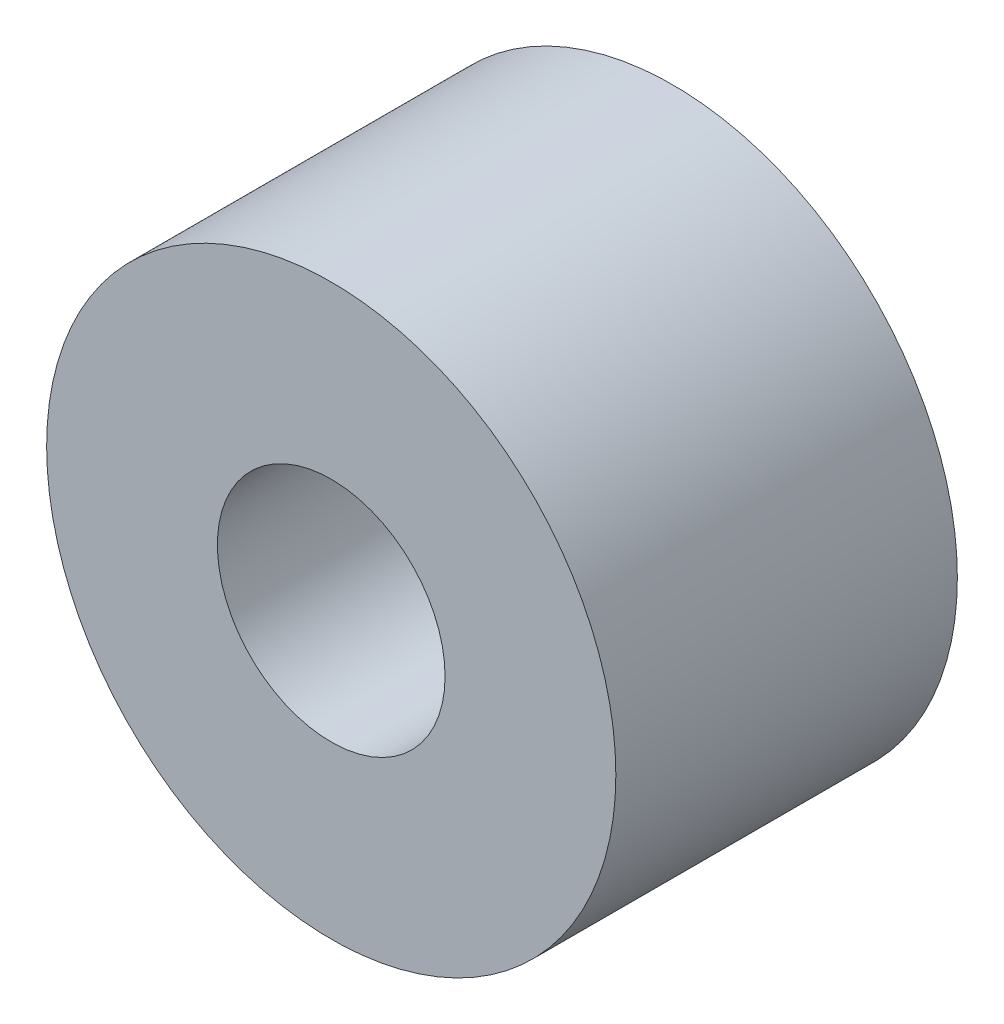
from build123d import *

# Parameters (mm, degrees)
IZIM1_R                     = 2.5
IZIM1_R_2                   = 1
Y_KSEKLIK_EKSTR_ZYON1_DEPTH = 3


with BuildPart() as part:
    # Çizim1 → Yükseklik-Ekstrüzyon1 (new body)
    with BuildSketch(Plane.XY):
        Circle(IZIM1_R)
        Circle(IZIM1_R_2, mode=Mode.SUBTRACT)
    extrude(amount=Y_KSEKLIK_EKSTR_ZYON1_DEPTH)


solid = part.part
